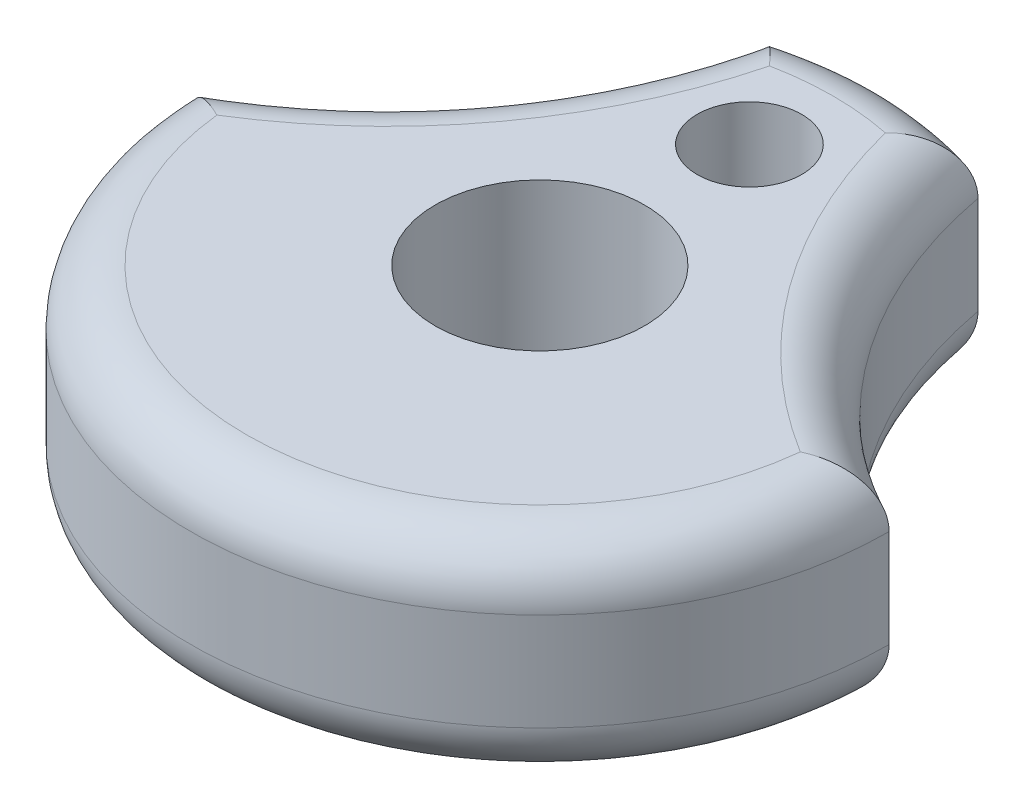
from build123d import *

# Parameters (mm, degrees)
SKETCH1_R           = 1.875
SKETCH1_R_2         = 0.935
BOSS_EXTRUDE1_DEPTH = 3.75
FILLET1_R           = 1
FILLET2_R           = 1


with BuildPart() as part:
    # Sketch1 → Boss-Extrude1 (new body)
    with BuildSketch(Plane(origin=(0, 0, 0), x_dir=(1, 0, 0), z_dir=(0, 1, 0))):
        with BuildLine():
            ThreePointArc((-6.25, 0), (0, -6.250030085), (6.25, 0))
            ThreePointArc((6.25, 0), (3.383257686, 2.480432696), (1.88, 5.960515192))
            ThreePointArc((1.88, 5.960515192), (0, 6.249969915), (-1.88, 5.960515192))
            ThreePointArc((-1.88, 5.960515192), (-3.383257686, 2.480432696), (-6.25, 0))
        make_face()
        with Locations((0, -3.0085e-05)):
            Circle(SKETCH1_R, mode=Mode.SUBTRACT)
        with Locations((0, 3.749969915)):
            Circle(SKETCH1_R_2, mode=Mode.SUBTRACT)
    extrude(amount=BOSS_EXTRUDE1_DEPTH)

    # Fillet1
    fillet1_edges = [part.edges().sort_by_distance(p)[0] for p in [
        (3.383257686, 3.75, -2.480432696),
        (0, 3.75, -6.249969915),
        (-3.383257686, 3.75, -2.480432696),
        (0, 3.75, 6.250030085),
    ]]
    fillet(fillet1_edges, radius=FILLET1_R)

    # Fillet2
    fillet2_edges = [part.edges().sort_by_distance(p)[0] for p in [
        (0, 0, -6.249969915),
        (3.383257686, 0, -2.480432696),
        (0, 0, 6.250030085),
        (-3.383257686, 0, -2.480432696),
    ]]
    fillet(fillet2_edges, radius=FILLET2_R)


solid = part.part
